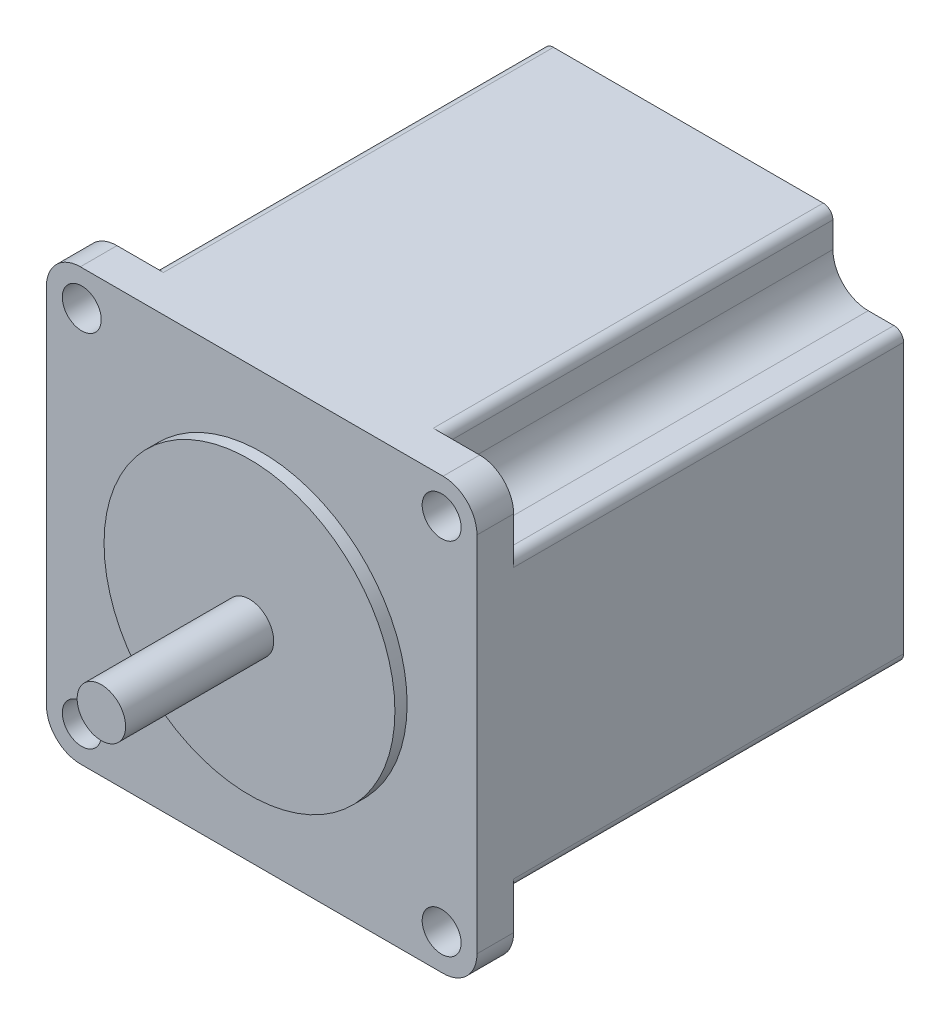
from build123d import *

# Parameters (mm, degrees)
SKETCH1_R           = 2.55
BOSS_EXTRUDE1_DEPTH = 4.8
BOSS_EXTRUDE2_DEPTH = 51.08
SKETCH3_R           = 19.05
BOSS_EXTRUDE3_DEPTH = 1.6
SKETCH4_R           = 3.175
BOSS_EXTRUDE8_DEPTH = 19.4


with BuildPart() as part:
    # Sketch1 → Boss-Extrude1 (new body)
    with BuildSketch(Plane.XY):
        with BuildLine():
            Line((-23.755, -28.2), (23.755, -28.2))
            ThreePointArc((23.755, -28.2), (26.898089642, -26.898089642), (28.2, -23.755))
            Line((28.2, -23.755), (28.2, 23.755))
            ThreePointArc((28.2, 23.755), (26.898089642, 26.898089642), (23.755, 28.2))
            Line((23.755, 28.2), (-23.755, 28.2))
            ThreePointArc((-23.755, 28.2), (-26.898089642, 26.898089642), (-28.2, 23.755))
            Line((-28.2, 23.755), (-28.2, -23.755))
            ThreePointArc((-28.2, -23.755), (-26.898089642, -26.898089642), (-23.755, -28.2))
        make_face()
        with Locations((-23.57, 23.57)):
            Circle(SKETCH1_R, mode=Mode.SUBTRACT)
        with Locations((23.57, 23.57)):
            Circle(SKETCH1_R, mode=Mode.SUBTRACT)
        with Locations((23.57, -23.57)):
            Circle(SKETCH1_R, mode=Mode.SUBTRACT)
        with Locations((-23.57, -23.57)):
            Circle(SKETCH1_R, mode=Mode.SUBTRACT)
    extrude(amount=BOSS_EXTRUDE1_DEPTH)

    # Sketch2 → Boss-Extrude2 (add)
    with BuildSketch(Plane(origin=(0, 0, 0), x_dir=(-1, 0, 0), z_dir=(0, 0, -1))):
        with BuildLine():
            Line((23.57, -18.94), (26.93, -18.94))
            ThreePointArc((26.93, -18.94), (27.828025612, -18.568025612), (28.2, -17.67))
            Line((28.2, -17.67), (28.2, 17.66630547))
            ThreePointArc((28.2, 17.66630547), (27.828025612, 18.564331082), (26.93, 18.93630547))
            Line((26.93, 18.93630547), (23.57, 18.93630547))
            ThreePointArc((23.57, 18.93630547), (20.293483176, 20.293483176), (18.93630547, 23.57))
            Line((18.93630547, 23.57), (18.93630547, 26.93))
            ThreePointArc((18.93630547, 26.93), (18.564331082, 27.828025612), (17.66630547, 28.2))
            Line((17.66630547, 28.2), (-17.67, 28.2))
            ThreePointArc((-17.67, 28.2), (-18.568025612, 27.828025612), (-18.94, 26.93))
            Line((-18.94, 26.93), (-18.94, 23.57))
            ThreePointArc((-18.94, 23.57), (-20.296095603, 20.296095603), (-23.57, 18.94))
            Line((-23.57, 18.94), (-26.93, 18.94))
            ThreePointArc((-26.93, 18.94), (-27.828025612, 18.568025612), (-28.2, 17.67))
            Line((-28.2, 17.67), (-28.2, -17.66630547))
            ThreePointArc((-28.2, -17.66630547), (-27.828025612, -18.564331082), (-26.93, -18.93630547))
            Line((-26.93, -18.93630547), (-23.57, -18.93630547))
            ThreePointArc((-23.57, -18.93630547), (-20.293483176, -20.293483176), (-18.93630547, -23.57))
            Line((-18.93630547, -23.57), (-18.93630547, -26.93))
            ThreePointArc((-18.93630547, -26.93), (-18.564331082, -27.828025612), (-17.66630547, -28.2))
            Line((-17.66630547, -28.2), (17.67, -28.2))
            ThreePointArc((17.67, -28.2), (18.568025612, -27.828025612), (18.94, -26.93))
            Line((18.94, -26.93), (18.94, -23.57))
            ThreePointArc((18.94, -23.57), (20.296095603, -20.296095603), (23.57, -18.94))
        make_face()
    extrude(amount=BOSS_EXTRUDE2_DEPTH)

    # Sketch3 → Boss-Extrude3 (add)
    with BuildSketch(Plane.XY.offset(4.8)):
        Circle(SKETCH3_R)
    extrude(amount=BOSS_EXTRUDE3_DEPTH)

    # Sketch4 → Boss-Extrude8 (add)
    with BuildSketch(Plane.XY.offset(6.4)):
        Circle(SKETCH4_R)
    extrude(amount=BOSS_EXTRUDE8_DEPTH)


solid = part.part
